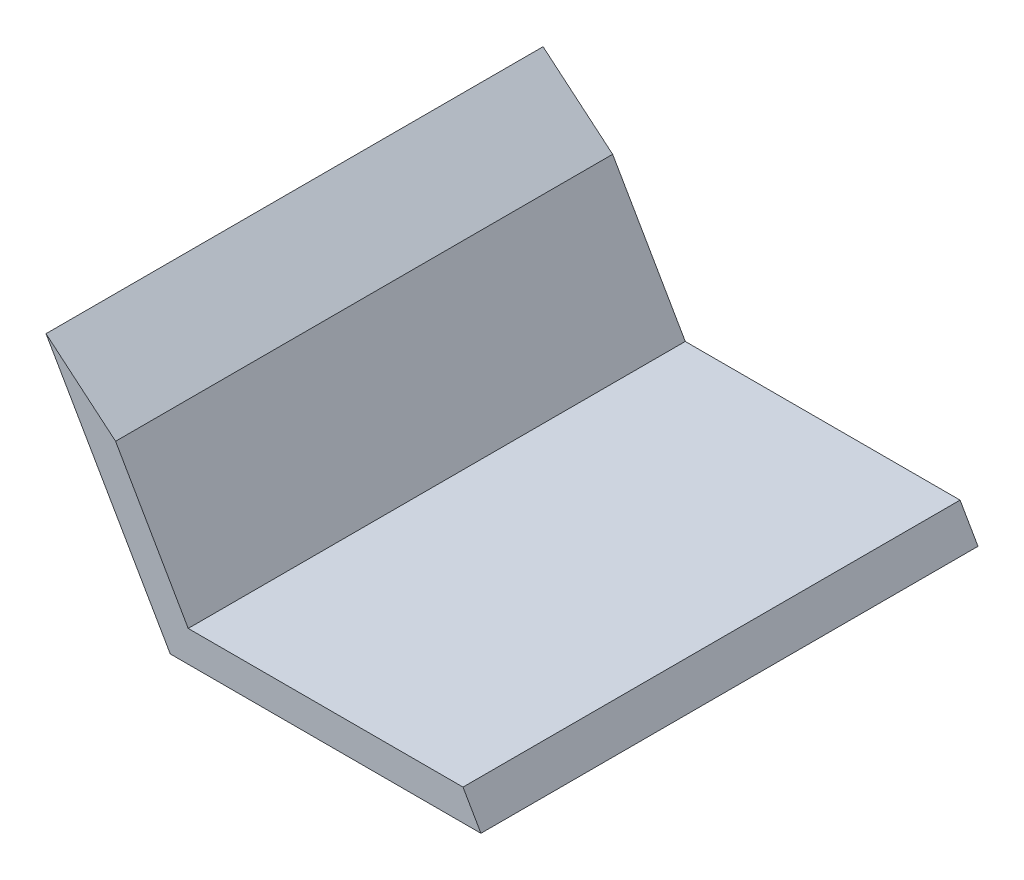
from build123d import *

# Parameters (mm, degrees)
BOSS_EXTRUDE1_DEPTH = 25.4
CUT_EXTRUDE1_DEPTH  = 26.4


with BuildPart() as part:
    # Sketch1 → Boss-Extrude1 (new body)
    with BuildSketch(Plane.XY):
        Polygon((0, 0), (-6.35, 10.998522628), (-4.516912895, 10.998522628), (0.916543552, 1.5875), (14.958456448, 1.5875), (15.875, 0), align=None)
    extrude(amount=BOSS_EXTRUDE1_DEPTH)

    # Sketch2 → Cut-Extrude1 (cut, through all)
    with BuildSketch(Plane.XY.offset(25.4)):
        Polygon((-6.35, 10.998522628), (-2.79437447, 8.014998557), (-4.516912895, 10.998522628), align=None)
    extrude(amount=-CUT_EXTRUDE1_DEPTH, mode=Mode.SUBTRACT)


solid = part.part
